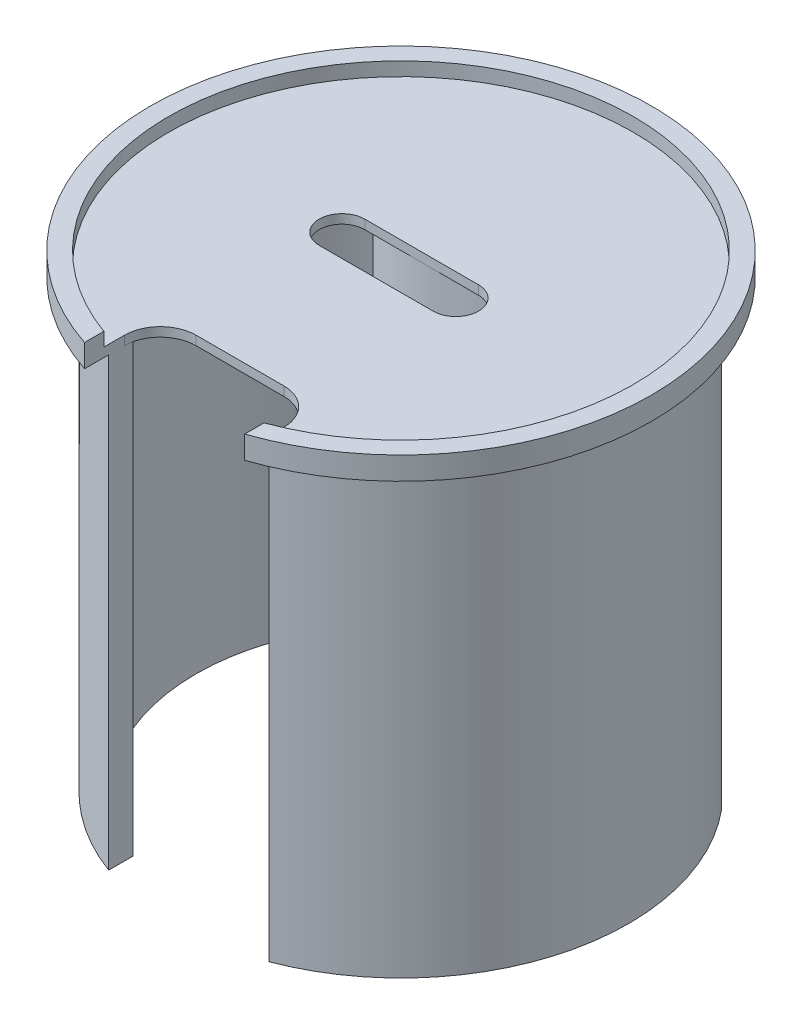
from build123d import *

# Parameters (mm, degrees)
SKETCH3_R           = 69.85
BOSS_EXTRUDE1_DEPTH = 6.35
SKETCH4_R           = 64.77
CUT_EXTRUDE1_DEPTH  = 3.81
SKETCH5_W           = 44.45
SKETCH5_H           = 25.4
CUT_EXTRUDE2_DEPTH  = 7.35
FILLET1_R           = 10
BOSS_EXTRUDE2_DEPTH = 82.55
BOSS_EXTRUDE3_DEPTH = 127


with BuildPart() as part:
    # Sketch3 → Boss-Extrude1 (new body)
    with BuildSketch(Plane(origin=(0, 0, 0), x_dir=(1, 0, 0), z_dir=(0, 1, 0))):
        Circle(SKETCH3_R)
        with BuildLine():
            Line((-16.448489627, 6.35), (15.301510373, 6.35))
            ThreePointArc((15.301510373, 6.35), (21.651510373, 0), (15.301510373, -6.35))
            Line((15.301510373, -6.35), (-16.448489627, -6.35))
            ThreePointArc((-16.448489627, -6.35), (-22.798489627, 0), (-16.448489627, 6.35))
        make_face(mode=Mode.SUBTRACT)
    extrude(amount=BOSS_EXTRUDE1_DEPTH)

    # Sketch4 → Cut-Extrude1 (cut)
    with BuildSketch(Plane(origin=(0, 6.35, 0), x_dir=(1, 0, 0), z_dir=(0, 1, 0))):
        Circle(SKETCH4_R)
    extrude(amount=-CUT_EXTRUDE1_DEPTH, mode=Mode.SUBTRACT)

    # Sketch5 → Cut-Extrude2 (cut, through all)
    with BuildSketch(Plane(origin=(0, 6.35, 0), x_dir=(1, 0, 0), z_dir=(0, 1, 0))):
        with Locations((0.312165283, -57.905331129)):
            Rectangle(SKETCH5_W, SKETCH5_H)
    extrude(amount=-CUT_EXTRUDE2_DEPTH, mode=Mode.SUBTRACT)

    # Fillet1
    fillet1_edges = [part.edges().sort_by_distance(p)[0] for p in [
        (22.537165283, 1.27, 45.205331129),
        (-21.912834717, 1.27, 45.205331129),
    ]]
    fillet(fillet1_edges, radius=FILLET1_R)

    # Sketch8 → Boss-Extrude2 (add)
    with BuildSketch(Plane.XZ):
        with BuildLine():
            Line((34.258206884, -40.64), (30.448206884, -40.64))
            ThreePointArc((30.448206884, -40.64), (0, -10.191793116), (-30.448206884, -40.64))
            Line((-30.448206884, -40.64), (-34.258206884, -40.64))
            ThreePointArc((-34.258206884, -40.64), (0, -6.381793116), (34.258206884, -40.64))
        make_face()
    extrude(amount=BOSS_EXTRUDE2_DEPTH)

    # Sketch11 → Boss-Extrude3 (add)
    with BuildSketch(Plane(origin=(0, 2.54, 0), x_dir=(1, 0, 0), z_dir=(0, 1, 0))):
        with BuildLine():
            ThreePointArc((-21.912834717, -52.782100893), (-56.087729184, -10.967640358), (-40.18100173, 40.64))
            Line((-40.18100173, 40.64), (-48.791806689, 40.64))
            ThreePointArc((-48.791806689, 40.64), (-61.333240284, -16.446386725), (-21.912834717, -59.599309347))
            Line((-21.912834717, -59.599309347), (-21.912834717, -55.205331129))
            Line((-21.912834717, -55.205331129), (-21.912834717, -52.782100893))
        make_face()
        with BuildLine():
            Line((48.791806689, 40.64), (40.18100173, 40.64))
            ThreePointArc((40.18100173, 40.64), (56.15176968, -10.634907703), (22.537165283, -52.518555588))
            Line((22.537165283, -52.518555588), (22.537165283, -55.205331129))
            Line((22.537165283, -55.205331129), (22.537165283, -59.366035584))
            ThreePointArc((22.537165283, -59.366035584), (61.418705204, -16.124287613), (48.791806689, 40.64))
        make_face()
    extrude(amount=-BOSS_EXTRUDE3_DEPTH)


solid = part.part
